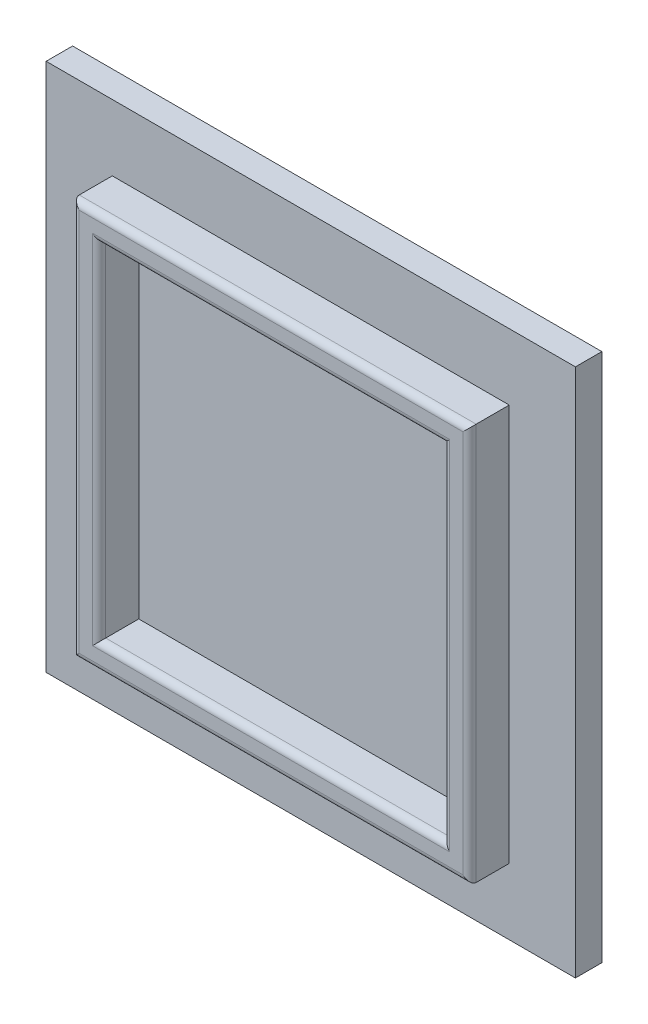
from build123d import *

# Parameters (mm, degrees)
SKETCH1_W           = 40
SKETCH1_H           = 40
BOSS_EXTRUDE1_DEPTH = 2
SKETCH2_W           = 30
SKETCH2_H           = 30
SKETCH2_W_2         = 26
SKETCH2_H_2         = 26
BOSS_EXTRUDE2_DEPTH = 3
FILLET2_R           = 0.5


with BuildPart() as part:
    # Sketch1 → Boss-Extrude1 (new body)
    with BuildSketch(Plane.XY):
        with Locations((-5.192307692, -4.855769231)):
            Rectangle(SKETCH1_W, SKETCH1_H)
    extrude(amount=BOSS_EXTRUDE1_DEPTH)

    # Sketch2 → Boss-Extrude2 (add)
    with BuildSketch(Plane.XY.offset(2)):
        with Locations((-5.192307692, -4.855769231)):
            Rectangle(SKETCH2_W, SKETCH2_H)
        with Locations((-5.192307692, -4.855769231)):
            Rectangle(SKETCH2_W_2, SKETCH2_H_2, mode=Mode.SUBTRACT)
    extrude(amount=BOSS_EXTRUDE2_DEPTH)

    # Fillet2
    fillet2_edges = [part.edges().sort_by_distance(p)[0] for p in [
        (-20.192307692, -4.855769231, 5),
        (-5.192307692, -19.855769231, 5),
        (9.807692308, -4.855769231, 5),
        (-5.192307692, 10.144230769, 5),
        (-18.192307692, -4.855769231, 5),
        (-5.192307692, -17.855769231, 5),
        (7.807692308, -4.855769231, 5),
        (-5.192307692, 8.144230769, 5),
    ]]
    fillet(fillet2_edges, radius=FILLET2_R)


solid = part.part
